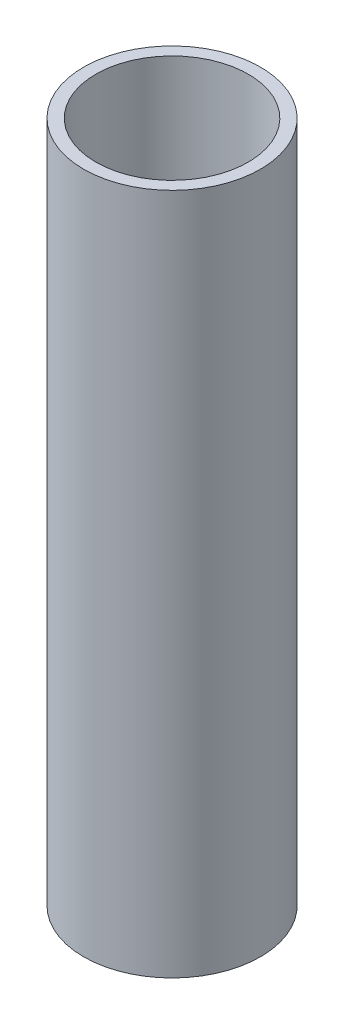
from build123d import *

# Parameters (mm, degrees)
SKETCH2_R           = 30.1625
SKETCH2_R_2         = 25.9969
BOSS_EXTRUDE1_DEPTH = 232.625


with BuildPart() as part:
    # Sketch2 → Boss-Extrude1 (new body)
    with BuildSketch(Plane(origin=(0, 0, 0), x_dir=(1, 0, 0), z_dir=(0, 1, 0))):
        Circle(SKETCH2_R)
        Circle(SKETCH2_R_2, mode=Mode.SUBTRACT)
    extrude(amount=BOSS_EXTRUDE1_DEPTH)


solid = part.part
